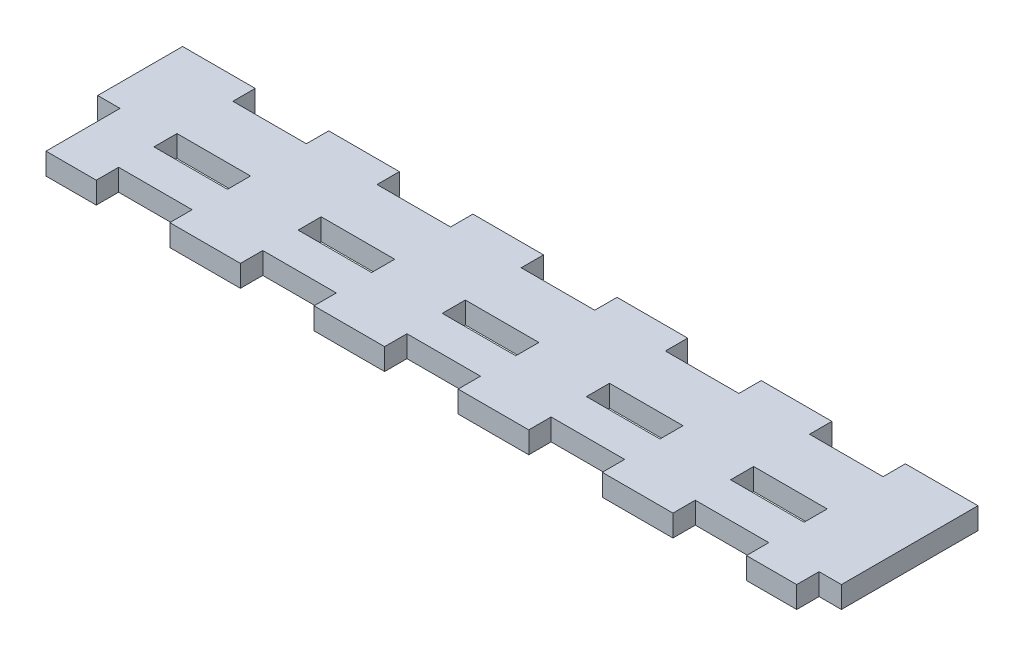
from build123d import *

# Parameters (mm, degrees)
SKETCH1_W           = 110.344434204
SKETCH1_H           = 22.05
BOSS_EXTRUDE1_DEPTH = 3
SKETCH3_W           = 10.2
SKETCH3_H           = 3.2
SKETCH3_W_2         = 3.2
SKETCH3_H_2         = 10.372217102
CUT_EXTRUDE1_DEPTH  = 4


with BuildPart() as part:
    # Sketch1 → Boss-Extrude1 (new body)
    with BuildSketch(Plane(origin=(0, 0, 0), x_dir=(1, 0, 0), z_dir=(0, 1, 0))):
        with Locations((0, -55.817990858)):
            Rectangle(SKETCH1_W, SKETCH1_H)
    extrude(amount=-BOSS_EXTRUDE1_DEPTH)

    # Sketch3 → Cut-Extrude1 (cut, through all)
    with BuildSketch(Plane(origin=(0, 0, 0), x_dir=(1, 0, 0), z_dir=(0, 1, 0))):
        with Locations((-40, -46.292990858)):
            Rectangle(SKETCH3_W, SKETCH3_H)
        with Locations((-53.672217102, -61.756882307)):
            Rectangle(SKETCH3_W_2, SKETCH3_H_2)
        with Locations((53.672217102, -65.342990858)):
            Rectangle(SKETCH3_W_2, SKETCH3_H)
        with Locations((-40, -65.342990858)):
            Rectangle(SKETCH3_W, SKETCH3_H)
        with Locations((-20, -46.292990858)):
            Rectangle(SKETCH3_W, SKETCH3_H)
        with Locations((-20, -65.342990858)):
            Rectangle(SKETCH3_W, SKETCH3_H)
        with Locations((0, -46.292990858)):
            Rectangle(SKETCH3_W, SKETCH3_H)
        with Locations((0, -65.342990858)):
            Rectangle(SKETCH3_W, SKETCH3_H)
        with Locations((20, -46.292990858)):
            Rectangle(SKETCH3_W, SKETCH3_H)
        with Locations((20, -65.342990858)):
            Rectangle(SKETCH3_W, SKETCH3_H)
        with Locations((40, -46.292990858)):
            Rectangle(SKETCH3_W, SKETCH3_H)
        with Locations((40, -65.342990858)):
            Rectangle(SKETCH3_W, SKETCH3_H)
        with Locations((-40, -57.242990858)):
            Rectangle(SKETCH3_W, SKETCH3_H)
        with Locations((40, -57.242990858)):
            Rectangle(SKETCH3_W, SKETCH3_H)
        with Locations((-20, -57.242990858)):
            Rectangle(SKETCH3_W, SKETCH3_H)
        with Locations((20, -57.242990858)):
            Rectangle(SKETCH3_W, SKETCH3_H)
        with Locations((0, -57.242990858)):
            Rectangle(SKETCH3_W, SKETCH3_H)
    extrude(amount=-CUT_EXTRUDE1_DEPTH, mode=Mode.SUBTRACT)


solid = part.part
